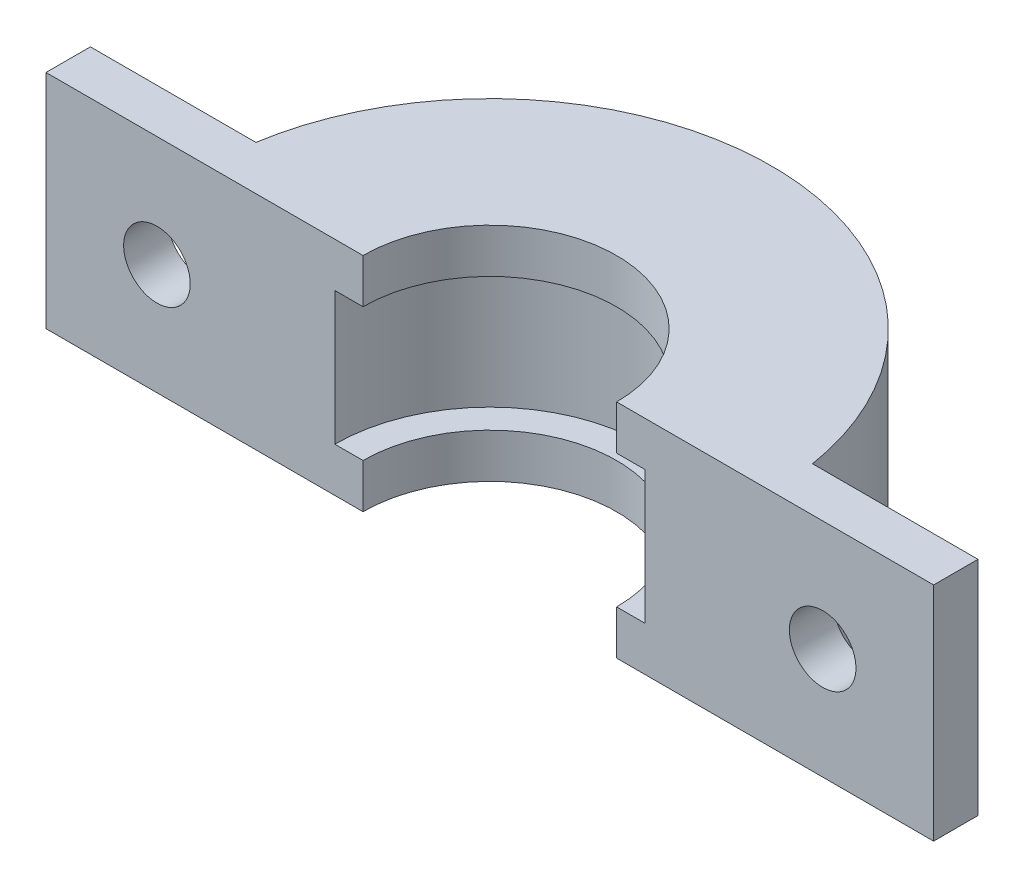
from build123d import *

# Parameters (mm, degrees)
BOSS_EXTRUDE1_DEPTH = 5
CUT_EXTRUDE1_DEPTH  = 3
SKETCH3_W           = 9
SKETCH3_H           = 10
SKETCH3_R           = 1.5
BOSS_EXTRUDE2_DEPTH = 2


with BuildPart() as part:
    # Sketch1 → Boss-Extrude1 (new body, symmetric)
    with BuildSketch(Plane(origin=(0, 0, 0), x_dir=(1, 0, 0), z_dir=(0, 1, 0))):
        with BuildLine():
            Line((5.715, 0), (12.7, 0))
            ThreePointArc((12.7, 0), (0, 12.7), (-12.7, 0))
            Line((-12.7, 0), (-5.715, 0))
            ThreePointArc((-5.715, 0), (0, 5.715), (5.715, 0))
        make_face()
    extrude(amount=BOSS_EXTRUDE1_DEPTH, both=True)

    # Sketch2 → Cut-Extrude1 (cut, symmetric)
    with BuildSketch(Plane(origin=(0, 0, 0), x_dir=(1, 0, 0), z_dir=(0, 1, 0))):
        with BuildLine():
            ThreePointArc((6.985, 0), (0, 6.985), (-6.985, 0))
            Line((-6.985, 0), (6.985, 0))
        make_face()
        with BuildLine():
            Line((6.985, 0), (-6.985, 0))
            ThreePointArc((-6.985, 0), (0, -6.985), (6.985, 0))
        make_face()
    extrude(amount=CUT_EXTRUDE1_DEPTH, both=True, mode=Mode.SUBTRACT)

    # Sketch3 → Boss-Extrude2 (add)
    with BuildSketch(Plane.XY):
        with Locations((15.5, 0)):
            Rectangle(SKETCH3_W, SKETCH3_H)
        with Locations((15, 0)):
            Circle(SKETCH3_R, mode=Mode.SUBTRACT)
        with Locations((-15.5, 0)):
            Rectangle(SKETCH3_W, SKETCH3_H)
        with Locations((-15, 0)):
            Circle(SKETCH3_R, mode=Mode.SUBTRACT)
    extrude(amount=-BOSS_EXTRUDE2_DEPTH)


solid = part.part
